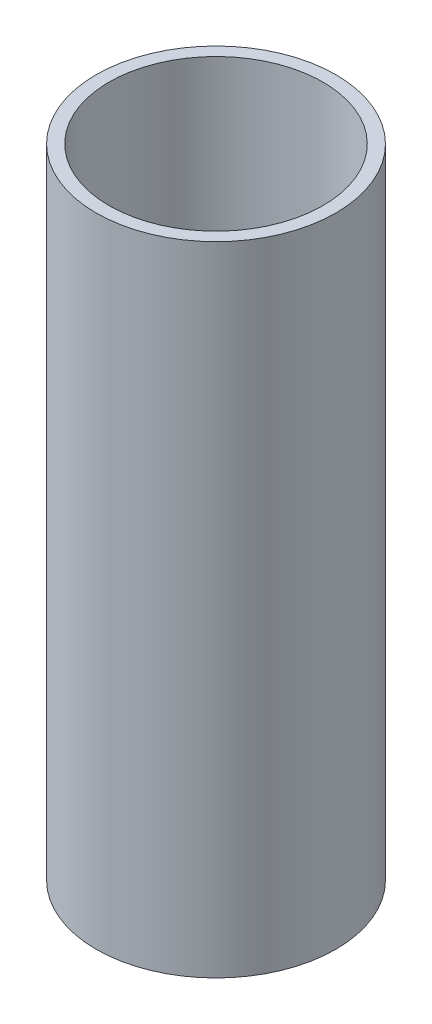
from build123d import *

# Parameters (mm, degrees)
SKETCH1_R           = 14
SKETCH1_R_2         = 12.5
BOSS_EXTRUDE1_DEPTH = 74.498
SCALE2_SCALE        = 0.5


with BuildPart() as part:
    # Sketch1 → Boss-Extrude1 (new body)
    with BuildSketch(Plane(origin=(0, 0, 0), x_dir=(1, 0, 0), z_dir=(0, 1, 0))):
        Circle(SKETCH1_R)
        Circle(SKETCH1_R_2, mode=Mode.SUBTRACT)
    extrude(amount=BOSS_EXTRUDE1_DEPTH)


with BuildPart() as part_1:
    # Scale2: scaled about (0, 37.249, 0)
    add(part.part.scale(SCALE2_SCALE).moved(Location((0, 18.6245, 0))))


solid = part_1.part
